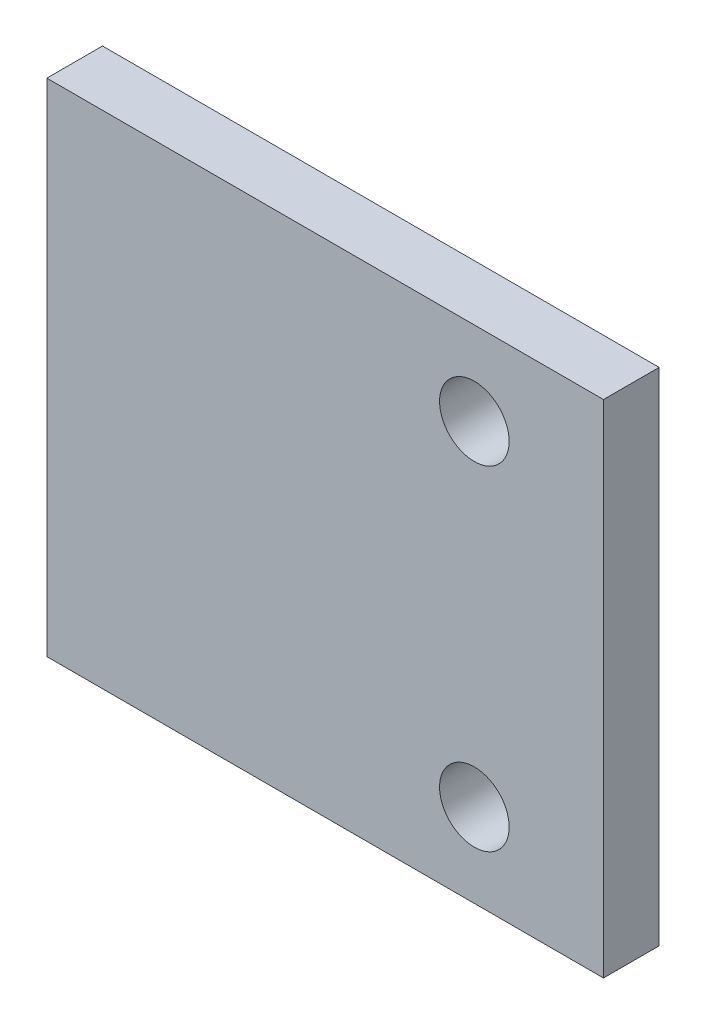
from build123d import *

# Parameters (mm, degrees)
ESQUISSE1_W        = 20
ESQUISSE1_H        = 18
ESQUISSE1_R        = 1.25
BOSS_EXTRU_1_DEPTH = 2


with BuildPart() as part:
    # Esquisse1 → Boss.-Extru.1 (new body)
    with BuildSketch(Plane.XY):
        with Locations((2.293336998, -4.150812065)):
            Rectangle(ESQUISSE1_W, ESQUISSE1_H)
        with Locations((7.652965768, 1.849187935)):
            Circle(ESQUISSE1_R, mode=Mode.SUBTRACT)
        with Locations((7.652965768, -10.150812065)):
            Circle(ESQUISSE1_R, mode=Mode.SUBTRACT)
    extrude(amount=BOSS_EXTRU_1_DEPTH)


solid = part.part
